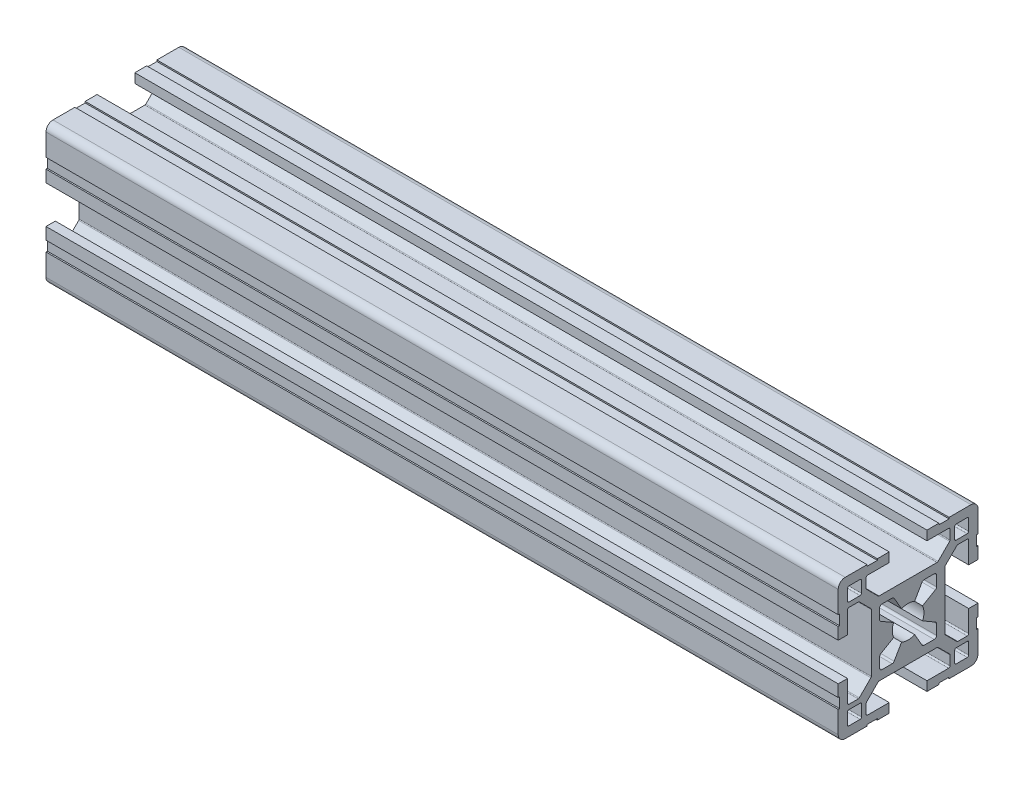
from build123d import *

# Parameters (mm, degrees)
QUADRADO_PF30_11_PERFIL_3030_CENTRO_M8_DEPTH = 170


with BuildPart() as part:
    # Sketch1 → Quadrado PF30-11 - PERFIL 3030 CENTRO M8(1) (new body)
    with BuildSketch(Plane.YZ):
        with BuildLine():
            Line((14.999995923, 6.599996803), (14.699995923, 6.599996803))
            Line((14.699995923, 6.599996803), (14.699995923, 8.799996803))
            Line((14.699995923, 8.799996803), (14.999995923, 8.799996803))
            Line((14.999995923, 8.799996803), (14.999995923, 13.499995825))
            ThreePointArc((14.999995923, 13.499995825), (14.560656066, 14.560656066), (13.499995825, 14.999995923))
            Line((13.499995825, 14.999995923), (8.799996818, 14.999995923))
            Line((8.799996818, 14.999995923), (8.799996818, 14.699995923))
            Line((8.799996818, 14.699995923), (6.599996818, 14.699995923))
            Line((6.599996818, 14.699995923), (6.599996818, 14.999995923))
            Line((6.599996818, 14.999995923), (4.0499987, 14.999995923))
            Line((4.0499987, 14.999995923), (4.0499987, 12.999995366))
            Line((4.0499987, 12.999995366), (8.699997649, 12.999995366))
            ThreePointArc((8.699997649, 12.999995366), (8.912129683, 12.9121274), (8.999997649, 12.699995366))
            Line((8.999997649, 12.699995366), (8.999997649, 10.679894006))
            ThreePointArc((8.999997649, 10.679894006), (8.977161511, 10.565088981), (8.912129691, 10.467761979))
            Line((8.912129691, 10.467761979), (6.432230191, 7.987862303))
            ThreePointArc((6.432230191, 7.987862303), (6.334903184, 7.922830472), (6.220098149, 7.89999433))
            Line((6.220098149, 7.89999433), (-6.220098149, 7.89999433))
            ThreePointArc((-6.220098149, 7.89999433), (-6.334903184, 7.922830472), (-6.432230191, 7.987862303))
            Line((-6.432230191, 7.987862303), (-8.912129691, 10.467761979))
            ThreePointArc((-8.912129691, 10.467761979), (-8.977161511, 10.565088981), (-8.999997649, 10.679894006))
            Line((-8.999997649, 10.679894006), (-8.999997649, 12.699995366))
            ThreePointArc((-8.999997649, 12.699995366), (-8.912129683, 12.9121274), (-8.699997649, 12.999995366))
            Line((-8.699997649, 12.999995366), (-4.0499987, 12.999995366))
            Line((-4.0499987, 12.999995366), (-4.0499987, 14.999995923))
            Line((-4.0499987, 14.999995923), (-6.599996818, 14.999995923))
            Line((-6.599996818, 14.999995923), (-6.599996818, 14.699995923))
            Line((-6.599996818, 14.699995923), (-8.799996818, 14.699995923))
            Line((-8.799996818, 14.699995923), (-8.799996818, 14.999995923))
            Line((-8.799996818, 14.999995923), (-13.499995825, 14.999995923))
            ThreePointArc((-13.499995825, 14.999995923), (-14.560656066, 14.560656066), (-14.999995923, 13.499995825))
            Line((-14.999995923, 13.499995825), (-14.999995923, 8.799996803))
            Line((-14.999995923, 8.799996803), (-14.699995923, 8.799996803))
            Line((-14.699995923, 8.799996803), (-14.699995923, 6.599996803))
            Line((-14.699995923, 6.599996803), (-14.999995923, 6.599996803))
            Line((-14.999995923, 6.599996803), (-14.999995923, 4.0499987))
            Line((-14.999995923, 4.0499987), (-12.999995366, 4.0499987))
            Line((-12.999995366, 4.0499987), (-12.999995366, 8.699997649))
            ThreePointArc((-12.999995366, 8.699997649), (-12.9121274, 8.912129683), (-12.699995366, 8.999997649))
            Line((-12.699995366, 8.999997649), (-10.679894006, 8.999997649))
            ThreePointArc((-10.679894006, 8.999997649), (-10.565088981, 8.977161511), (-10.467761979, 8.912129691))
            Line((-10.467761979, 8.912129691), (-7.987862303, 6.432230191))
            ThreePointArc((-7.987862303, 6.432230191), (-7.922830472, 6.334903184), (-7.89999433, 6.220098149))
            Line((-7.89999433, 6.220098149), (-7.89999433, -6.220098149))
            ThreePointArc((-7.89999433, -6.220098149), (-7.922830472, -6.334903184), (-7.987862303, -6.432230191))
            Line((-7.987862303, -6.432230191), (-10.467761979, -8.912129691))
            ThreePointArc((-10.467761979, -8.912129691), (-10.565088981, -8.977161511), (-10.679894006, -8.999997649))
            Line((-10.679894006, -8.999997649), (-12.699995366, -8.999997649))
            ThreePointArc((-12.699995366, -8.999997649), (-12.9121274, -8.912129683), (-12.999995366, -8.699997649))
            Line((-12.999995366, -8.699997649), (-12.999995366, -4.0499987))
            Line((-12.999995366, -4.0499987), (-14.999995923, -4.0499987))
            Line((-14.999995923, -4.0499987), (-14.999995923, -6.599996803))
            Line((-14.999995923, -6.599996803), (-14.699995923, -6.599996803))
            Line((-14.699995923, -6.599996803), (-14.699995923, -8.799996803))
            Line((-14.699995923, -8.799996803), (-14.999995923, -8.799996803))
            Line((-14.999995923, -8.799996803), (-14.999995923, -13.499995825))
            ThreePointArc((-14.999995923, -13.499995825), (-14.560656066, -14.560656066), (-13.499995825, -14.999995923))
            Line((-13.499995825, -14.999995923), (-8.799996818, -14.999995923))
            Line((-8.799996818, -14.999995923), (-8.799996818, -14.699995923))
            Line((-8.799996818, -14.699995923), (-6.599996818, -14.699995923))
            Line((-6.599996818, -14.699995923), (-6.599996818, -14.999995923))
            Line((-6.599996818, -14.999995923), (-4.0499987, -14.999995923))
            Line((-4.0499987, -14.999995923), (-4.0499987, -12.999995366))
            Line((-4.0499987, -12.999995366), (-8.699997649, -12.999995366))
            ThreePointArc((-8.699997649, -12.999995366), (-8.912129683, -12.9121274), (-8.999997649, -12.699995366))
            Line((-8.999997649, -12.699995366), (-8.999997649, -10.679894006))
            ThreePointArc((-8.999997649, -10.679894006), (-8.977161511, -10.565088981), (-8.912129691, -10.467761979))
            Line((-8.912129691, -10.467761979), (-6.432230191, -7.987862303))
            ThreePointArc((-6.432230191, -7.987862303), (-6.334903184, -7.922830472), (-6.220098149, -7.89999433))
            Line((-6.220098149, -7.89999433), (6.220098149, -7.89999433))
            ThreePointArc((6.220098149, -7.89999433), (6.334903184, -7.922830472), (6.432230191, -7.987862303))
            Line((6.432230191, -7.987862303), (8.912129691, -10.467761979))
            ThreePointArc((8.912129691, -10.467761979), (8.977161511, -10.565088981), (8.999997649, -10.679894006))
            Line((8.999997649, -10.679894006), (8.999997649, -12.699995366))
            ThreePointArc((8.999997649, -12.699995366), (8.912129683, -12.9121274), (8.699997649, -12.999995366))
            Line((8.699997649, -12.999995366), (4.0499987, -12.999995366))
            Line((4.0499987, -12.999995366), (4.0499987, -14.999995923))
            Line((4.0499987, -14.999995923), (6.599996818, -14.999995923))
            Line((6.599996818, -14.999995923), (6.599996818, -14.699995923))
            Line((6.599996818, -14.699995923), (8.799996818, -14.699995923))
            Line((8.799996818, -14.699995923), (8.799996818, -14.999995923))
            Line((8.799996818, -14.999995923), (13.499995825, -14.999995923))
            ThreePointArc((13.499995825, -14.999995923), (14.560656066, -14.560656066), (14.999995923, -13.499995825))
            Line((14.999995923, -13.499995825), (14.999995923, -8.799996803))
            Line((14.999995923, -8.799996803), (14.699995923, -8.799996803))
            Line((14.699995923, -8.799996803), (14.699995923, -6.599996803))
            Line((14.699995923, -6.599996803), (14.999995923, -6.599996803))
            Line((14.999995923, -6.599996803), (14.999995923, -4.0499987))
            Line((14.999995923, -4.0499987), (12.999995366, -4.0499987))
            Line((12.999995366, -4.0499987), (12.999995366, -8.699997649))
            ThreePointArc((12.999995366, -8.699997649), (12.9121274, -8.912129683), (12.699995366, -8.999997649))
            Line((12.699995366, -8.999997649), (10.679894006, -8.999997649))
            ThreePointArc((10.679894006, -8.999997649), (10.565088981, -8.977161511), (10.467761979, -8.912129691))
            Line((10.467761979, -8.912129691), (7.987862303, -6.432230191))
            ThreePointArc((7.987862303, -6.432230191), (7.922830472, -6.334903184), (7.89999433, -6.220098149))
            Line((7.89999433, -6.220098149), (7.89999433, 6.220098149))
            ThreePointArc((7.89999433, 6.220098149), (7.922830472, 6.334903184), (7.987862303, 6.432230191))
            Line((7.987862303, 6.432230191), (10.467761979, 8.912129691))
            ThreePointArc((10.467761979, 8.912129691), (10.565088981, 8.977161511), (10.679894006, 8.999997649))
            Line((10.679894006, 8.999997649), (12.699995366, 8.999997649))
            ThreePointArc((12.699995366, 8.999997649), (12.9121274, 8.912129683), (12.999995366, 8.699997649))
            Line((12.999995366, 8.699997649), (12.999995366, 4.0499987))
            Line((12.999995366, 4.0499987), (14.999995923, 4.0499987))
            Line((14.999995923, 4.0499987), (14.999995923, 6.599996803))
        make_face()
        with BuildLine():
            Line((-6.1, -3.425408784), (-6.1, -5.6))
            ThreePointArc((-6.1, -5.6), (-5.953553391, -5.953553391), (-5.6, -6.1))
            Line((-5.6, -6.1), (-3.425408784, -6.1))
            ThreePointArc((-3.425408784, -6.1), (-3.175408784, -6.033012702), (-2.992396082, -5.85))
            Line((-2.992396082, -5.85), (-1.402974441, -3.097040962))
            ThreePointArc((-1.402974441, -3.097040962), (0, -3.4), (1.402974441, -3.097040962))
            Line((1.402974441, -3.097040962), (2.992396082, -5.85))
            ThreePointArc((2.992396082, -5.85), (3.175408784, -6.033012702), (3.425408784, -6.1))
            Line((3.425408784, -6.1), (5.6, -6.1))
            ThreePointArc((5.6, -6.1), (5.953553391, -5.953553391), (6.1, -5.6))
            Line((6.1, -5.6), (6.1, -3.425408784))
            ThreePointArc((6.1, -3.425408784), (6.033012702, -3.175408784), (5.85, -2.992396082))
            Line((5.85, -2.992396082), (3.097040962, -1.402974441))
            ThreePointArc((3.097040962, -1.402974441), (3.4, 0), (3.097040962, 1.402974441))
            Line((3.097040962, 1.402974441), (5.85, 2.992396082))
            ThreePointArc((5.85, 2.992396082), (6.033012702, 3.175408784), (6.1, 3.425408784))
            Line((6.1, 3.425408784), (6.1, 5.6))
            ThreePointArc((6.1, 5.6), (5.953553391, 5.953553391), (5.6, 6.1))
            Line((5.6, 6.1), (3.425408784, 6.1))
            ThreePointArc((3.425408784, 6.1), (3.175408784, 6.033012702), (2.992396082, 5.85))
            Line((2.992396082, 5.85), (1.402974441, 3.097040962))
            ThreePointArc((1.402974441, 3.097040962), (0, 3.4), (-1.402974441, 3.097040962))
            Line((-1.402974441, 3.097040962), (-2.992396082, 5.85))
            ThreePointArc((-2.992396082, 5.85), (-3.175408784, 6.033012702), (-3.425408784, 6.1))
            Line((-3.425408784, 6.1), (-5.6, 6.1))
            ThreePointArc((-5.6, 6.1), (-5.953553391, 5.953553391), (-6.1, 5.6))
            Line((-6.1, 5.6), (-6.1, 3.425408784))
            ThreePointArc((-6.1, 3.425408784), (-6.033012702, 3.175408784), (-5.85, 2.992396082))
            Line((-5.85, 2.992396082), (-3.097040962, 1.402974441))
            ThreePointArc((-3.097040962, 1.402974441), (-3.4, 0), (-3.097040962, -1.402974441))
            Line((-3.097040962, -1.402974441), (-5.85, -2.992396082))
            ThreePointArc((-5.85, -2.992396082), (-6.033012702, -3.175408784), (-6.1, -3.425408784))
        make_face(mode=Mode.SUBTRACT)
        with BuildLine():
            Line((9.999995366, 12.699997649), (9.999995366, 10.299997649))
            ThreePointArc((9.999995366, 10.299997649), (10.087863331, 10.087865615), (10.299995366, 9.999997649))
            Line((10.299995366, 9.999997649), (12.699995366, 9.999997649))
            ThreePointArc((12.699995366, 9.999997649), (12.9121274, 10.087865615), (12.999995366, 10.299997649))
            Line((12.999995366, 10.299997649), (12.999995366, 12.699997649))
            ThreePointArc((12.999995366, 12.699997649), (12.9121274, 12.912129683), (12.699995366, 12.999997649))
            Line((12.699995366, 12.999997649), (10.299995366, 12.999997649))
            ThreePointArc((10.299995366, 12.999997649), (10.087863331, 12.912129683), (9.999995366, 12.699997649))
        make_face(mode=Mode.SUBTRACT)
        with BuildLine():
            Line((12.999995366, -12.699997649), (12.999995366, -10.299997649))
            ThreePointArc((12.999995366, -10.299997649), (12.9121274, -10.087865615), (12.699995366, -9.999997649))
            Line((12.699995366, -9.999997649), (10.299995366, -9.999997649))
            ThreePointArc((10.299995366, -9.999997649), (10.087863331, -10.087865615), (9.999995366, -10.299997649))
            Line((9.999995366, -10.299997649), (9.999995366, -12.699997649))
            ThreePointArc((9.999995366, -12.699997649), (10.087863331, -12.912129683), (10.299995366, -12.999997649))
            Line((10.299995366, -12.999997649), (12.699995366, -12.999997649))
            ThreePointArc((12.699995366, -12.999997649), (12.9121274, -12.912129683), (12.999995366, -12.699997649))
        make_face(mode=Mode.SUBTRACT)
        with BuildLine():
            Line((-10.299995366, -9.999997649), (-12.699995366, -9.999997649))
            ThreePointArc((-12.699995366, -9.999997649), (-12.9121274, -10.087865615), (-12.999995366, -10.299997649))
            Line((-12.999995366, -10.299997649), (-12.999995366, -12.699997649))
            ThreePointArc((-12.999995366, -12.699997649), (-12.9121274, -12.912129683), (-12.699995366, -12.999997649))
            Line((-12.699995366, -12.999997649), (-10.299995366, -12.999997649))
            ThreePointArc((-10.299995366, -12.999997649), (-10.087863331, -12.912129683), (-9.999995366, -12.699997649))
            Line((-9.999995366, -12.699997649), (-9.999995366, -10.299997649))
            ThreePointArc((-9.999995366, -10.299997649), (-10.087863331, -10.087865615), (-10.299995366, -9.999997649))
        make_face(mode=Mode.SUBTRACT)
        with BuildLine():
            Line((-12.999995366, 12.699997649), (-12.999995366, 10.299997649))
            ThreePointArc((-12.999995366, 10.299997649), (-12.9121274, 10.087865615), (-12.699995366, 9.999997649))
            Line((-12.699995366, 9.999997649), (-10.299995366, 9.999997649))
            ThreePointArc((-10.299995366, 9.999997649), (-10.087863331, 10.087865615), (-9.999995366, 10.299997649))
            Line((-9.999995366, 10.299997649), (-9.999995366, 12.699997649))
            ThreePointArc((-9.999995366, 12.699997649), (-10.087863331, 12.912129683), (-10.299995366, 12.999997649))
            Line((-10.299995366, 12.999997649), (-12.699995366, 12.999997649))
            ThreePointArc((-12.699995366, 12.999997649), (-12.9121274, 12.912129683), (-12.999995366, 12.699997649))
        make_face(mode=Mode.SUBTRACT)
    extrude(amount=QUADRADO_PF30_11_PERFIL_3030_CENTRO_M8_DEPTH)


solid = part.part
